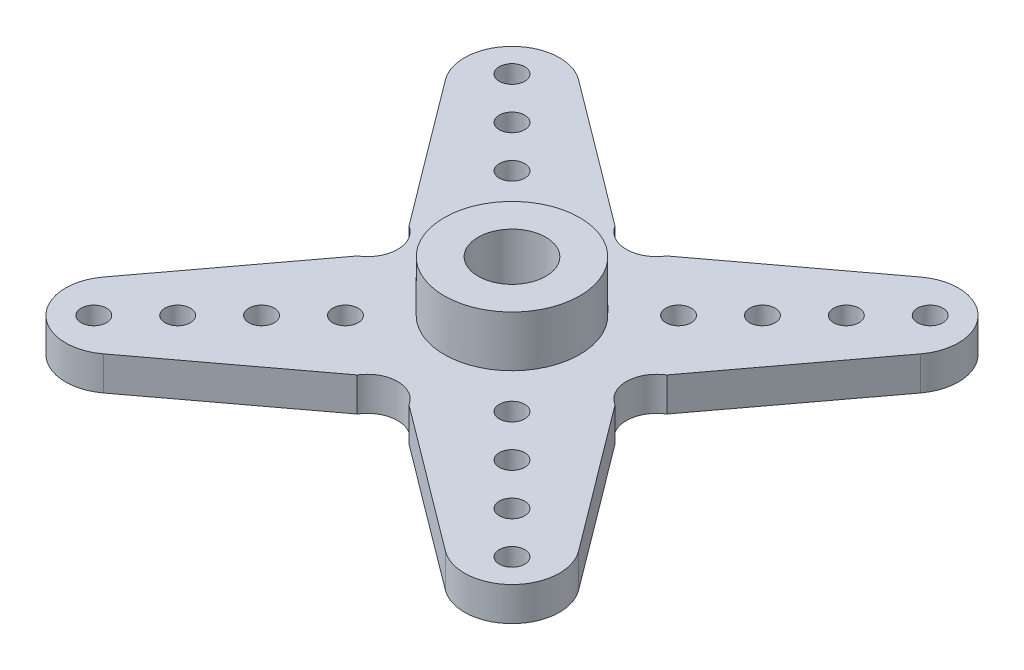
from build123d import *

# Parameters (mm, degrees)
BOSS_EXTRUDE1_DEPTH         = 2
SKETCH5_R                   = 4
SKETCH5_R_2                 = 1.998542518
BOSS_EXTRUDE2_DEPTH         = 3
SKETCH8_R                   = 1.5
CUT_EXTRUDE2_DEPTH          = 6
SKETCH9_R                   = 3.6
SKETCH9_R_2                 = 3
BOSS_EXTRUDE3_DEPTH         = 0.85
SKETCH10_R                  = 0.75
CUT_EXTRUDE3_DEPTH          = 2
LPATTERN1_COUNT             = 4
LPATTERN1_PITCH             = 3.5
CIRPATTERN1_COUNT           = 4
CIRPATTERN1_COPY_1_SKETCH_R = 0.75
CIRPATTERN1_COPY_1_DEPTH    = 2
CIRPATTERN1_COPY_2_SKETCH_R = 0.75
CIRPATTERN1_COPY_2_DEPTH    = 2
CIRPATTERN1_COPY_3_SKETCH_R = 0.75
CIRPATTERN1_COPY_3_DEPTH    = 2
CIRPATTERN1_COPY_4_SKETCH_R = 0.75
CIRPATTERN1_COPY_4_DEPTH    = 2
CIRPATTERN1_COPY_5_SKETCH_R = 0.75
CIRPATTERN1_COPY_5_DEPTH    = 2
CIRPATTERN1_COPY_6_SKETCH_R = 0.75
CIRPATTERN1_COPY_6_DEPTH    = 2
CIRPATTERN1_COPY_7_SKETCH_R = 0.75
CIRPATTERN1_COPY_7_DEPTH    = 2
CIRPATTERN1_COPY_8_SKETCH_R = 0.75
CIRPATTERN1_COPY_8_DEPTH    = 2
CIRPATTERN1_COPY_9_SKETCH_R = 0.75
CIRPATTERN1_COPY_9_DEPTH    = 2


with BuildPart() as part:
    # Sketch1 → Boss-Extrude1 (new body)
    with BuildSketch(Plane(origin=(0, 0, 0), x_dir=(1, 0, 0), z_dir=(0, 1, 0))):
        with BuildLine():
            Line((11.195476756, 1.969359322), (4.786657556, -6.592741724))
            ThreePointArc((4.786657556, -6.592741724), (3.929987754, -8.118293207), (4.786657556, -9.643844691))
            Line((4.786657556, -9.643844691), (11.195476756, -18.205945736))
            ThreePointArc((11.195476756, -18.205945736), (10.933214648, -21.871520101), (7.267640283, -22.133782209))
            Line((7.267640283, -22.133782209), (-1.294460762, -15.724963009))
            ThreePointArc((-1.294460762, -15.724963009), (-2.820012246, -14.868293207), (-4.34556373, -15.724963009))
            Line((-4.34556373, -15.724963009), (-12.907664775, -22.133782209))
            ThreePointArc((-12.907664775, -22.133782209), (-16.57323914, -21.871520101), (-16.835501248, -18.205945736))
            Line((-16.835501248, -18.205945736), (-10.426682048, -9.643844691))
            ThreePointArc((-10.426682048, -9.643844691), (-9.570012246, -8.118293207), (-10.426682048, -6.592741724))
            Line((-10.426682048, -6.592741724), (-16.835501248, 1.969359322))
            ThreePointArc((-16.835501248, 1.969359322), (-16.57323914, 5.634933687), (-12.907664775, 5.897195795))
            Line((-12.907664775, 5.897195795), (-4.34556373, -0.511623405))
            ThreePointArc((-4.34556373, -0.511623405), (-2.820012246, -1.368293207), (-1.294460762, -0.511623405))
            Line((-1.294460762, -0.511623405), (7.267640283, 5.897195795))
            ThreePointArc((7.267640283, 5.897195795), (10.933214648, 5.634933687), (11.195476756, 1.969359322))
        make_face()
    extrude(amount=BOSS_EXTRUDE1_DEPTH)

    # Sketch5 → Boss-Extrude2 (add)
    with BuildSketch(Plane(origin=(0, 2, 0), x_dir=(1, 0, 0), z_dir=(0, 1, 0))):
        with Locations((-2.820012246, -8.118293207)):
            Circle(SKETCH5_R)
        with Locations((-2.820012246, -8.118293207)):
            Circle(SKETCH5_R_2, mode=Mode.SUBTRACT)
    extrude(amount=BOSS_EXTRUDE2_DEPTH)

    # Sketch8 → Cut-Extrude2 (cut, through all)
    with BuildSketch(Plane.XZ):
        with Locations((-2.820012246, 8.118293207)):
            Circle(SKETCH8_R)
    extrude(amount=-CUT_EXTRUDE2_DEPTH, mode=Mode.SUBTRACT)

    # Sketch9 → Boss-Extrude3 (add)
    with BuildSketch(Plane.XZ):
        with Locations((-2.820012246, 8.118293207)):
            Circle(SKETCH9_R)
        with Locations((-2.820012246, 8.118293207)):
            Circle(SKETCH9_R_2, mode=Mode.SUBTRACT)
    extrude(amount=BOSS_EXTRUDE3_DEPTH)

    # Sketch10 → Cut-Extrude3 (cut)
    with BuildSketch(Plane.XZ):
        with Locations((9.519001086, -4.220720125)):
            Circle(SKETCH10_R)
    cut_extrude3 = extrude(amount=-CUT_EXTRUDE3_DEPTH, mode=Mode.SUBTRACT)

    # LPattern1: Cut-Extrude3 ×4
    with Locations(*[Vector(-0.707106781, 0, 0.707106781) * (i * LPATTERN1_PITCH) for i in range(1, LPATTERN1_COUNT)]):
        add(cut_extrude3, mode=Mode.SUBTRACT)

    # CirPattern1: Cut-Extrude3 ×4 about axis
    cirpattern1_axis = Axis((-2.820012246, 0, 8.118293207), (0, 1, 0))
    for i in range(1, CIRPATTERN1_COUNT):
        add(cut_extrude3.rotate(cirpattern1_axis, i * 360 / CIRPATTERN1_COUNT), mode=Mode.SUBTRACT)

    # CirPattern1 copy 1 sketch → CirPattern1 copy 1 (cut)
    with BuildSketch(Plane(origin=(-8.463431719, 0, 7.773154695), x_dir=(0, 0, -1), z_dir=(0, -1, 0))):
        with Locations((9.519001086, -4.220720125)):
            Circle(CIRPATTERN1_COPY_1_SKETCH_R)
    extrude(amount=-CIRPATTERN1_COPY_1_DEPTH, mode=Mode.SUBTRACT)

    # CirPattern1 copy 2 sketch → CirPattern1 copy 2 (cut)
    with BuildSketch(Plane(origin=(-3.165150758, 0, 13.76171268), x_dir=(-1, 0, 0), z_dir=(0, -1, 0))):
        with Locations((9.519001086, -4.220720125)):
            Circle(CIRPATTERN1_COPY_2_SKETCH_R)
    extrude(amount=-CIRPATTERN1_COPY_2_DEPTH, mode=Mode.SUBTRACT)

    # CirPattern1 copy 3 sketch → CirPattern1 copy 3 (cut)
    with BuildSketch(Plane(origin=(2.823407227, 0, 8.463431719), x_dir=(0, 0, 1), z_dir=(0, -1, 0))):
        with Locations((9.519001086, -4.220720125)):
            Circle(CIRPATTERN1_COPY_3_SKETCH_R)
    extrude(amount=-CIRPATTERN1_COPY_3_DEPTH, mode=Mode.SUBTRACT)

    # CirPattern1 copy 4 sketch → CirPattern1 copy 4 (cut)
    with BuildSketch(Plane(origin=(-5.988557985, 0, 10.248028429), x_dir=(0, 0, -1), z_dir=(0, -1, 0))):
        with Locations((9.519001086, -4.220720125)):
            Circle(CIRPATTERN1_COPY_4_SKETCH_R)
    extrude(amount=-CIRPATTERN1_COPY_4_DEPTH, mode=Mode.SUBTRACT)

    # CirPattern1 copy 5 sketch → CirPattern1 copy 5 (cut)
    with BuildSketch(Plane(origin=(-0.690277024, 0, 11.286838946), x_dir=(-1, 0, 0), z_dir=(0, -1, 0))):
        with Locations((9.519001086, -4.220720125)):
            Circle(CIRPATTERN1_COPY_5_SKETCH_R)
    extrude(amount=-CIRPATTERN1_COPY_5_DEPTH, mode=Mode.SUBTRACT)

    # CirPattern1 copy 6 sketch → CirPattern1 copy 6 (cut)
    with BuildSketch(Plane(origin=(0.348533493, 0, 5.988557985), x_dir=(0, 0, 1), z_dir=(0, -1, 0))):
        with Locations((9.519001086, -4.220720125)):
            Circle(CIRPATTERN1_COPY_6_SKETCH_R)
    extrude(amount=-CIRPATTERN1_COPY_6_DEPTH, mode=Mode.SUBTRACT)

    # CirPattern1 copy 7 sketch → CirPattern1 copy 7 (cut)
    with BuildSketch(Plane(origin=(-3.513684251, 0, 12.722902164), x_dir=(0, 0, -1), z_dir=(0, -1, 0))):
        with Locations((9.519001086, -4.220720125)):
            Circle(CIRPATTERN1_COPY_7_SKETCH_R)
    extrude(amount=-CIRPATTERN1_COPY_7_DEPTH, mode=Mode.SUBTRACT)

    # CirPattern1 copy 8 sketch → CirPattern1 copy 8 (cut)
    with BuildSketch(Plane(origin=(1.78459671, 0, 8.811965212), x_dir=(-1, 0, 0), z_dir=(0, -1, 0))):
        with Locations((9.519001086, -4.220720125)):
            Circle(CIRPATTERN1_COPY_8_SKETCH_R)
    extrude(amount=-CIRPATTERN1_COPY_8_DEPTH, mode=Mode.SUBTRACT)

    # CirPattern1 copy 9 sketch → CirPattern1 copy 9 (cut)
    with BuildSketch(Plane(origin=(-2.126340241, 0, 3.513684251), x_dir=(0, 0, 1), z_dir=(0, -1, 0))):
        with Locations((9.519001086, -4.220720125)):
            Circle(CIRPATTERN1_COPY_9_SKETCH_R)
    extrude(amount=-CIRPATTERN1_COPY_9_DEPTH, mode=Mode.SUBTRACT)


solid = part.part
